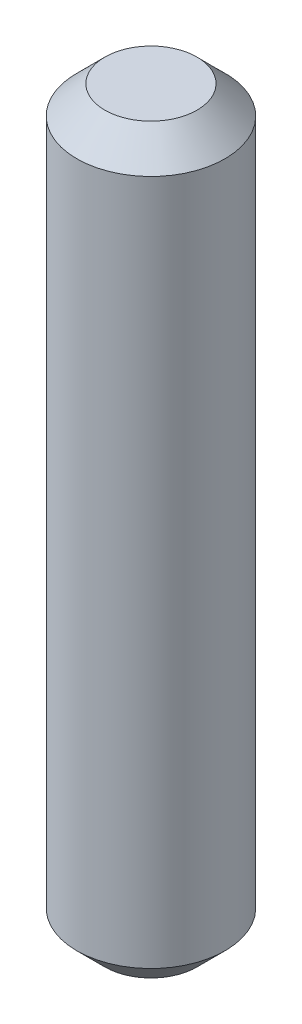
from build123d import *

# Parameters (mm, degrees)
SKETCH1_R           = 1.585
BOSS_EXTRUDE1_DEPTH = 7.935
CHAMFER1_SIZE       = 0.6


with BuildPart() as part:
    # Sketch1 → Boss-Extrude1 (new body, symmetric)
    with BuildSketch(Plane(origin=(0, 0, 0), x_dir=(1, 0, 0), z_dir=(0, 1, 0))):
        Circle(SKETCH1_R)
    extrude(amount=BOSS_EXTRUDE1_DEPTH, both=True)

    # Chamfer1
    chamfer1_edges = [part.edges().sort_by_distance(p)[0] for p in [
        (-1.585, -7.935, 0),
        (-1.585, 7.935, 0),
    ]]
    chamfer(chamfer1_edges, length=CHAMFER1_SIZE)


solid = part.part
